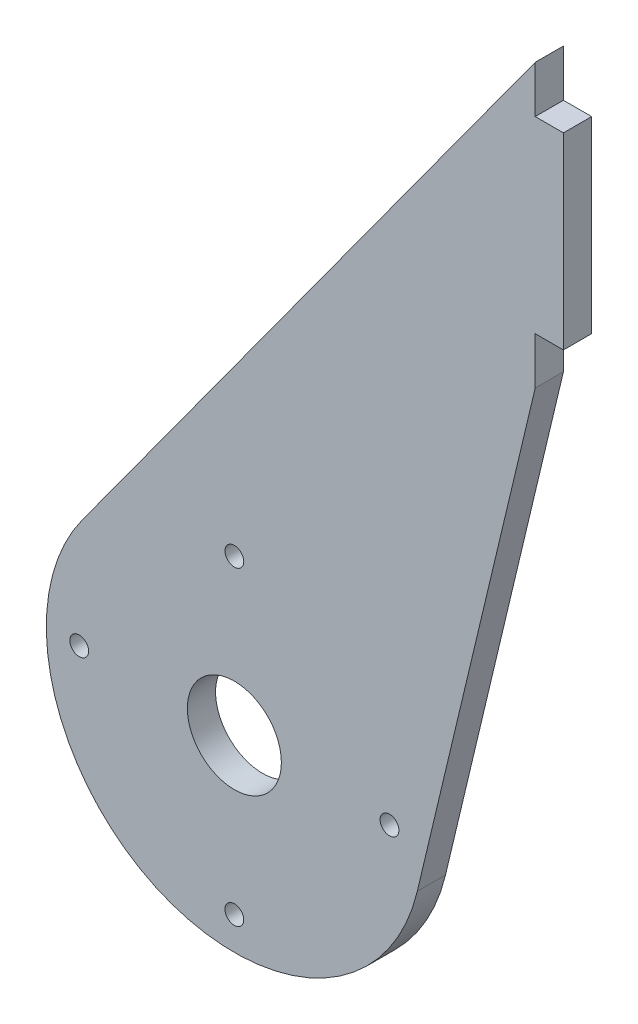
from build123d import *

# Parameters (mm, degrees)
SKETCH1_R           = 1
BOSS_EXTRUDE1_DEPTH = 3
SKETCH2_R           = 5
CUT_EXTRUDE1_DEPTH  = 10
SKETCH4_W           = 3
SKETCH4_H           = 20
BOSS_EXTRUDE3_DEPTH = 3


with BuildPart() as part:
    # Sketch1 → Boss-Extrude1 (new body)
    with BuildSketch(Plane.XY):
        with BuildLine():
            Line((-16.174411119, 11.763860972), (32, 78))
            Line((32, 78), (32, 48))
            Line((32, 48), (19.455095298, -4.636730199))
            ThreePointArc((19.455095298, -4.636730199), (-8.362748941, -18.167675419), (-16.174411119, 11.763860972))
        make_face()
        with Locations((0, 16.5)):
            Circle(SKETCH1_R, mode=Mode.SUBTRACT)
        with Locations((-16.5, 0)):
            Circle(SKETCH1_R, mode=Mode.SUBTRACT)
        with Locations((0, -16.5)):
            Circle(SKETCH1_R, mode=Mode.SUBTRACT)
        with Locations((16.5, 0)):
            Circle(SKETCH1_R, mode=Mode.SUBTRACT)
    extrude(amount=-BOSS_EXTRUDE1_DEPTH)

    # Sketch2 → Cut-Extrude1 (cut)
    with BuildSketch(Plane.XY):
        Circle(SKETCH2_R)
    extrude(amount=-CUT_EXTRUDE1_DEPTH, mode=Mode.SUBTRACT)

    # Sketch4 → Boss-Extrude3 (add)
    with BuildSketch(Plane(origin=(32, 0, 0), x_dir=(0, 0, -1), z_dir=(1, 0, 0))):
        with Locations((1.5, 63)):
            Rectangle(SKETCH4_W, SKETCH4_H)
    extrude(amount=BOSS_EXTRUDE3_DEPTH)


solid = part.part
